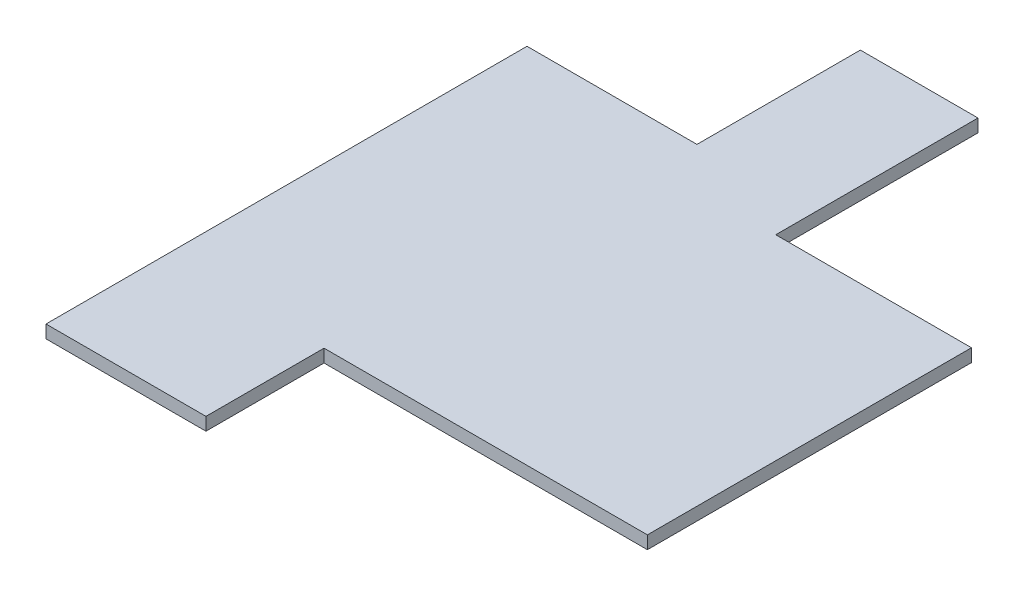
from build123d import *

# Parameters (mm, degrees)
BOSS_EXTRU_1_DEPTH = 0.4


with BuildPart() as part:
    # Esquisse1 → Boss.-Extru.1 (new body, symmetric)
    with BuildSketch(Plane(origin=(0, 0, 0), x_dir=(1, 0, 0), z_dir=(0, 1, 0))):
        Polygon((-15, -20), (-5.070958152, -20), (-5.070958152, -12.669744809), (15, -12.669744809), (15, 7.44690143), (2.85169362, 7.44690143), (2.85169362, 20), (-4.450924535, 20), (-4.450924535, 9.858143274), (-15, 9.858143274), align=None)
    extrude(amount=BOSS_EXTRU_1_DEPTH, both=True)


solid = part.part
